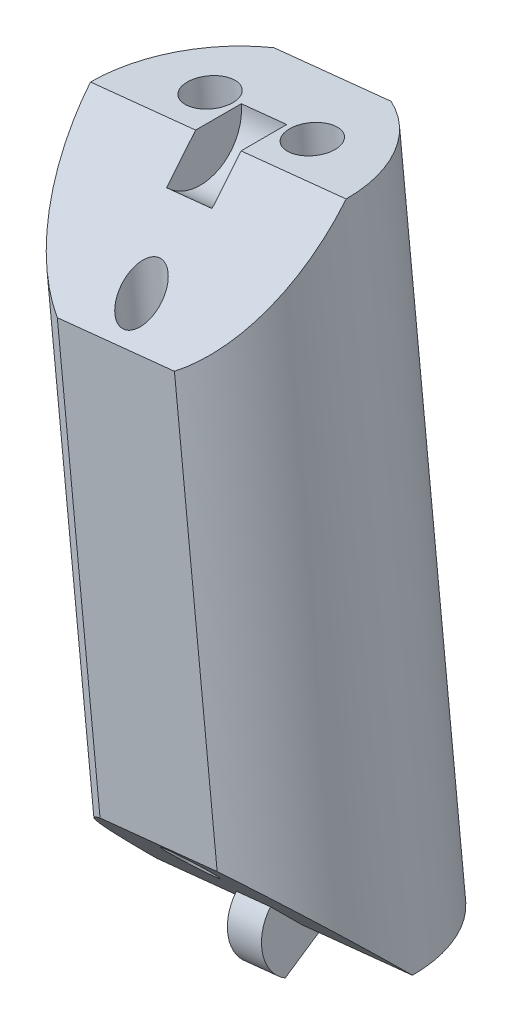
from build123d import *

# Parameters (mm, degrees)
SKETCH3_R               = 9
BOSS_EXTRUDE1_DEPTH     = 45
CUT_EXTRUDE1_DEPTH      = 14.617013191
CUT_EXTRUDE1_DEPTH_BACK = 14.617013191
BOSS_EXTRUDE2_DEPTH     = 1.2
CUT_EXTRUDE2_DEPTH      = 1.6
SKETCH8_R               = 1.6
SKETCH8_R_2             = 1.4
CUT_EXTRUDE3_DEPTH      = 2.846805277
CUT_EXTRUDE3_DEPTH_BACK = 49.445593418
CUT_EXTRUDE4_DEPTH      = 47.846805277


with BuildPart() as part:
    # Sketch3 → Boss-Extrude1 (new body)
    with BuildSketch(Plane(origin=(-20.344467381, 196.178792599, 0), x_dir=(-0.994665758, -0.103150523, 0), z_dir=(0.103150523, -0.994665758, 0))):
        with Locations((-10.431405186, 0)):
            Circle(SKETCH3_R)
    extrude(amount=BOSS_EXTRUDE1_DEPTH)

    # Sketch4 → Cut-Extrude1 (cut, two sides)
    with BuildSketch(Plane(origin=(10.375761543, 1.076004901, 0), x_dir=(0.103150523, -0.994665758, 0), z_dir=(-0.994665758, -0.103150523, 0))) as cut_extrude1_sk:
        Polygon((-197.230869842, 0), (-188.230869842, 9), (-197.230869842, 9), align=None)
        Polygon((-161.230869842, 9), (-152.230869842, 9), (-152.230869842, 0), align=None)
    extrude(amount=CUT_EXTRUDE1_DEPTH, mode=Mode.SUBTRACT)
    extrude(cut_extrude1_sk.sketch, amount=-CUT_EXTRUDE1_DEPTH_BACK, mode=Mode.SUBTRACT)

    # Sketch5 → Boss-Extrude2 (add, symmetric)
    with BuildSketch(Plane(origin=(10.375761543, 1.076004901, 0), x_dir=(0.103150523, -0.994665758, 0), z_dir=(-0.994665758, -0.103150523, 0))):
        with BuildLine():
            Line((-152.230869842, 0), (-154.210768829, 1.979898987))
            ThreePointArc((-154.210768829, 1.979898987), (-151.865396504, 2.776045612), (-149.805998711, 1.4))
            Line((-149.805998711, 1.4), (-152.230869842, -2.8))
            Line((-152.230869842, -2.8), (-152.230869842, 0))
        make_face()
    extrude(amount=BOSS_EXTRUDE2_DEPTH, both=True)

    # Sketch7 → Cut-Extrude2 (cut, symmetric)
    with BuildSketch(Plane(origin=(10.375761543, 1.076004901, 0), x_dir=(0.103150523, -0.994665758, 0), z_dir=(-0.994665758, -0.103150523, 0))):
        with BuildLine():
            Line((-194.968128142, 2.2627417), (-197.230869842, 0))
            Line((-197.230869842, 0), (-197.230869842, -3.2))
            ThreePointArc((-197.230869842, -3.2), (-194.274455338, -1.224586984), (-194.968128142, 2.2627417))
        make_face()
    extrude(amount=CUT_EXTRUDE2_DEPTH, both=True, mode=Mode.SUBTRACT)

    # Sketch8 → Cut-Extrude3 (cut, two sides)
    with BuildSketch(Plane(origin=(-20.344467381, 196.178792599, 0), x_dir=(0.994665758, 0.103150523, 0), z_dir=(-0.103150523, 0.994665758, 0))) as cut_extrude3_sk:
        with Locations((6.831405186, 3)):
            Circle(SKETCH8_R)
        with Locations((14.031405186, 3)):
            Circle(SKETCH8_R)
        with Locations((10.431405186, -6)):
            Circle(SKETCH8_R_2)
    extrude(amount=CUT_EXTRUDE3_DEPTH, mode=Mode.SUBTRACT)
    extrude(cut_extrude3_sk.sketch, amount=-CUT_EXTRUDE3_DEPTH_BACK, mode=Mode.SUBTRACT)

    # Sketch9 → Cut-Extrude4 (cut, through all)
    with BuildSketch(Plane(origin=(-15.702693845, 151.418833501, 0), x_dir=(0.994665758, 0.103150523, 0), z_dir=(0.103150523, -0.994665758, 0))):
        with BuildLine():
            Line((6.30829956, -8), (14.554510811, -8))
            ThreePointArc((14.554510811, -8), (10.431405186, -9), (6.30829956, -8))
        make_face()
        with BuildLine():
            Line((14.554510811, 8), (6.30829956, 8))
            ThreePointArc((6.30829956, 8), (10.431405186, 9), (14.554510811, 8))
        make_face()
    extrude(amount=-CUT_EXTRUDE4_DEPTH, mode=Mode.SUBTRACT)


solid = part.part
